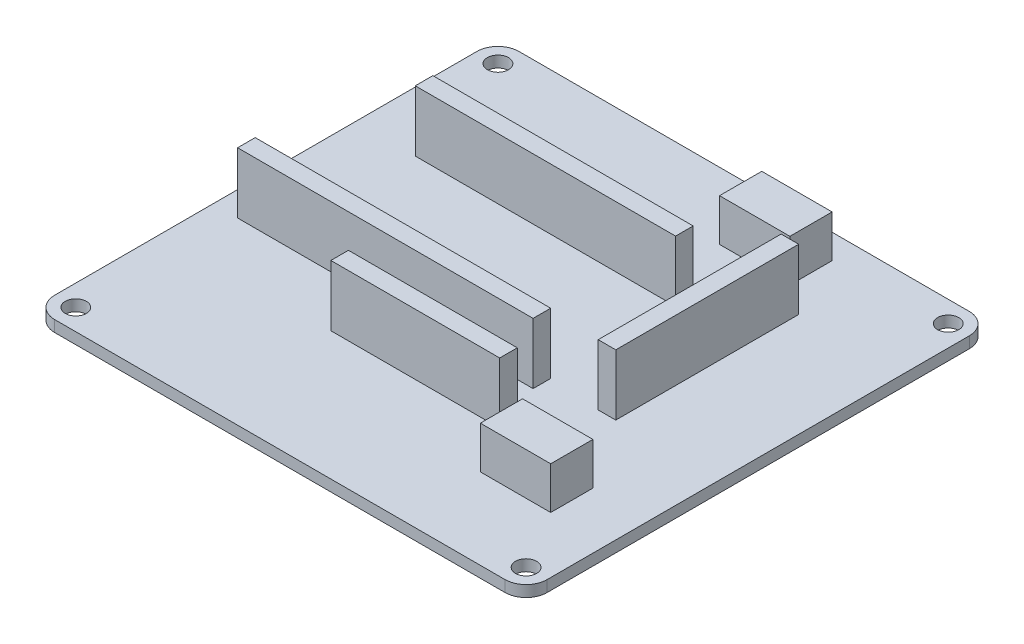
from build123d import *

# Parameters (mm, degrees)
SKETCH1_R           = 1.5
BOSS_EXTRUDE1_DEPTH = 1.6
SKETCH2_W           = 10
SKETCH2_H           = 6
BOSS_EXTRUDE3_DEPTH = 6
SKETCH2_7_W         = 37
SKETCH2_7_H         = 2.5
SKETCH2_7_W_2       = 42
SKETCH2_7_W_3       = 2.5
SKETCH2_7_H_2       = 26
SKETCH2_7_W_4       = 24
BOSS_EXTRUDE4_DEPTH = 8.65


with BuildPart() as part:
    # Sketch1 → Boss-Extrude1 (new body)
    with BuildSketch(Plane(origin=(0, 0, 0), x_dir=(1, 0, 0), z_dir=(0, 1, 0))):
        with BuildLine():
            Line((-32, 33), (32, 33))
            ThreePointArc((32, 33), (34.121320344, 32.121320344), (35, 30))
            Line((35, 30), (35, -30))
            ThreePointArc((35, -30), (34.121320344, -32.121320344), (32, -33))
            Line((32, -33), (-32, -33))
            ThreePointArc((-32, -33), (-34.121320344, -32.121320344), (-35, -30))
            Line((-35, -30), (-35, 30))
            ThreePointArc((-35, 30), (-34.121320344, 32.121320344), (-32, 33))
        make_face()
        with Locations((-32, 30)):
            Circle(SKETCH1_R, mode=Mode.SUBTRACT)
        with Locations((32, 30)):
            Circle(SKETCH1_R, mode=Mode.SUBTRACT)
        with Locations((32, -30)):
            Circle(SKETCH1_R, mode=Mode.SUBTRACT)
        with Locations((-32, -30)):
            Circle(SKETCH1_R, mode=Mode.SUBTRACT)
    extrude(amount=BOSS_EXTRUDE1_DEPTH)

    # Sketch2 → Boss-Extrude3 (add)
    with BuildSketch(Plane(origin=(0, 1.6, 0), x_dir=(1, 0, 0), z_dir=(0, 1, 0))):
        with Locations((11, 26.5)):
            Rectangle(SKETCH2_W, SKETCH2_H)
        with Locations((22, -18.5)):
            Rectangle(SKETCH2_W, SKETCH2_H)
    extrude(amount=BOSS_EXTRUDE3_DEPTH)

    # Sketch2_7 → Boss-Extrude4 (add)
    with BuildSketch(Plane(origin=(0, 1.6, 0), x_dir=(1, 0, 0), z_dir=(0, 1, 0))):
        with Locations((-8, 14)):
            Rectangle(SKETCH2_7_W, SKETCH2_7_H)
        with Locations((-10.5, -6.25)):
            Rectangle(SKETCH2_7_W_2, SKETCH2_7_H)
        with Locations((19, 7.5)):
            Rectangle(SKETCH2_7_W_3, SKETCH2_7_H_2)
        with Locations((1, -13.5)):
            Rectangle(SKETCH2_7_W_4, SKETCH2_7_H)
    extrude(amount=BOSS_EXTRUDE4_DEPTH)


solid = part.part
